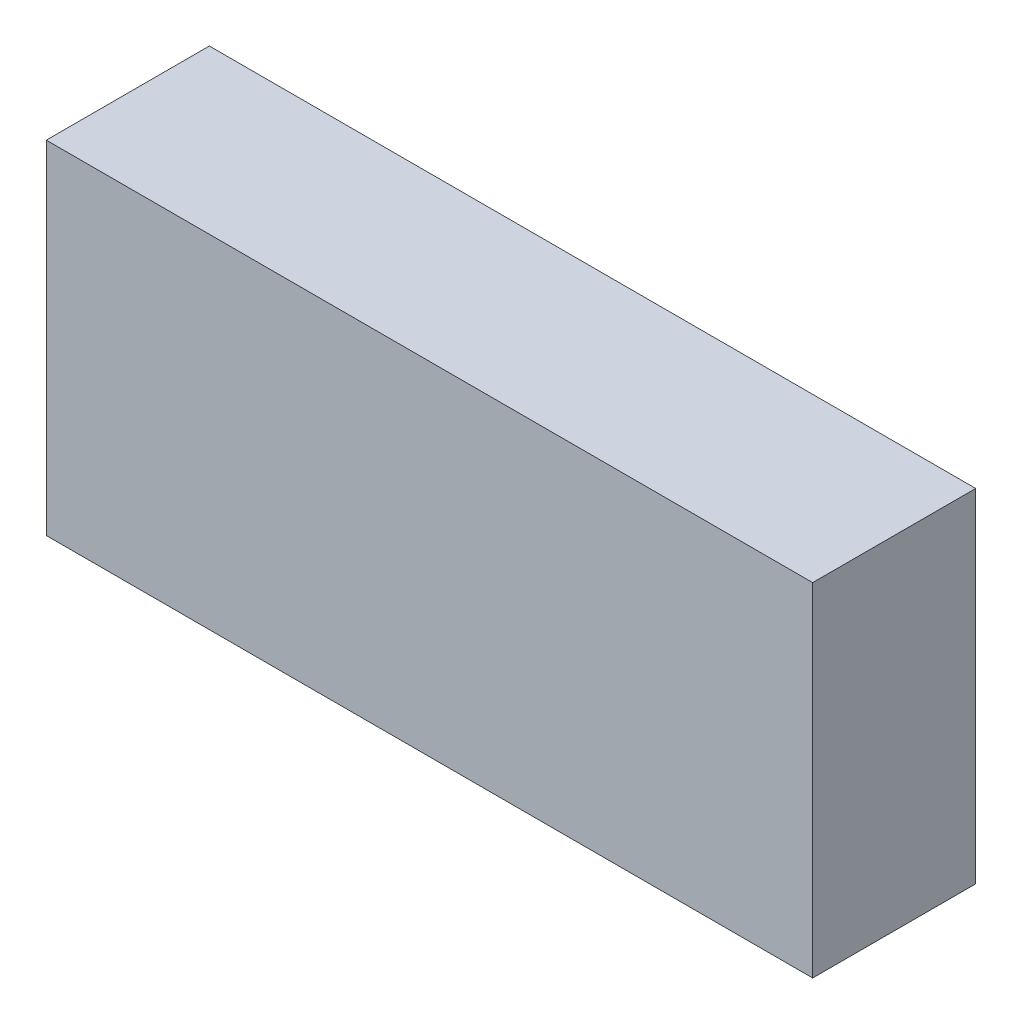
from build123d import *

# Parameters (mm, degrees)
SKETCH1_W           = 23.5
SKETCH1_H           = 10.5
BOSS_EXTRUDE1_DEPTH = 5


with BuildPart() as part:
    # Sketch1 → Boss-Extrude1 (new body)
    with BuildSketch(Plane.XY):
        with Locations((11.75, -5.25)):
            Rectangle(SKETCH1_W, SKETCH1_H)
    extrude(amount=BOSS_EXTRUDE1_DEPTH)


solid = part.part
